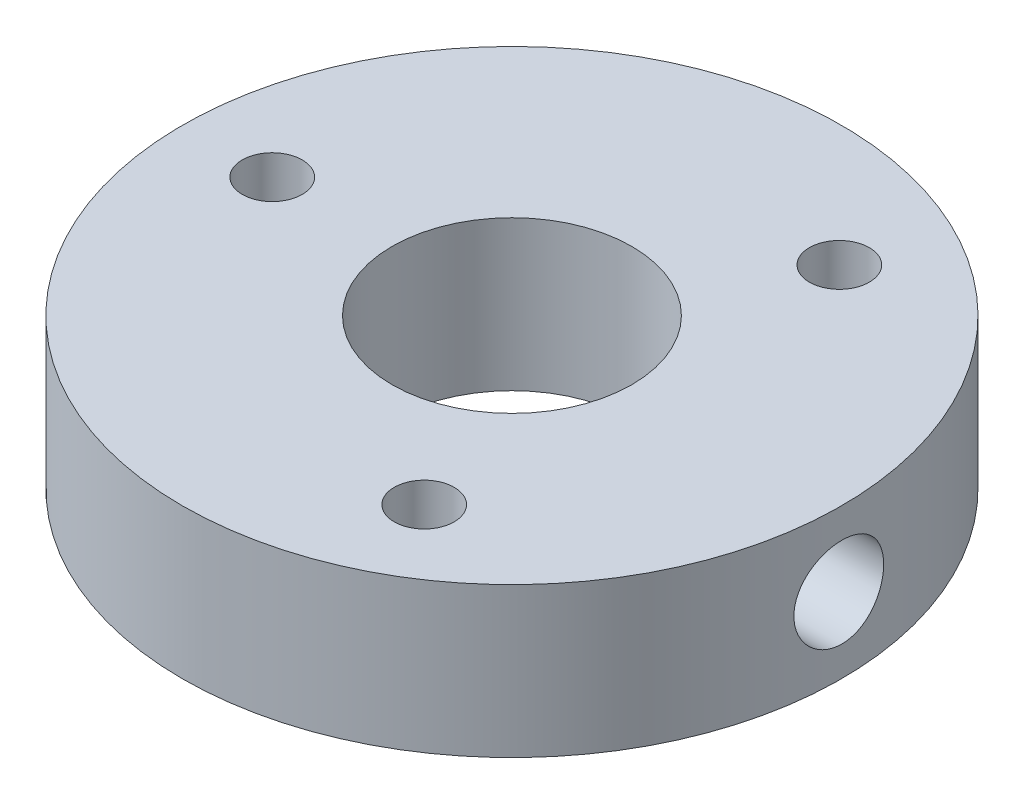
from build123d import *

# Parameters (mm, degrees)
SKETCH1_R               = 11
SKETCH1_R_2             = 4
SKETCH1_R_3             = 1
BOSS_EXTRUDE1_DEPTH     = 5
CUT_EXTRUDE1_DEPTH      = 10
CUT_EXTRUDE1_DEPTH_BACK = 10
SKETCH2_R               = 1.5


with BuildPart() as part:
    # Sketch1 → Boss-Extrude1 (new body)
    with BuildSketch(Plane(origin=(0, 0, 0), x_dir=(1, 0, 0), z_dir=(0, 1, 0))):
        Circle(SKETCH1_R)
        Circle(SKETCH1_R_2, mode=Mode.SUBTRACT)
        with Locations((-8, 0)):
            Circle(SKETCH1_R_3, mode=Mode.SUBTRACT)
        with Locations((4, 6.92820323)):
            Circle(SKETCH1_R_3, mode=Mode.SUBTRACT)
        with Locations((4, -6.92820323)):
            Circle(SKETCH1_R_3, mode=Mode.SUBTRACT)
    extrude(amount=BOSS_EXTRUDE1_DEPTH)

    # Sketch2 → Cut-Extrude1 (cut, two sides: drawn at the far end of the back side and taken through both)
    with BuildSketch(Plane(origin=(10.998674606, 0, 0), x_dir=(0, 0, -1), z_dir=(1, 0, 0)).offset(-CUT_EXTRUDE1_DEPTH_BACK)):
        with Locations((0.011578062, 2.49997319)):
            Circle(SKETCH2_R)
    extrude(amount=CUT_EXTRUDE1_DEPTH + CUT_EXTRUDE1_DEPTH_BACK, mode=Mode.SUBTRACT)


solid = part.part
